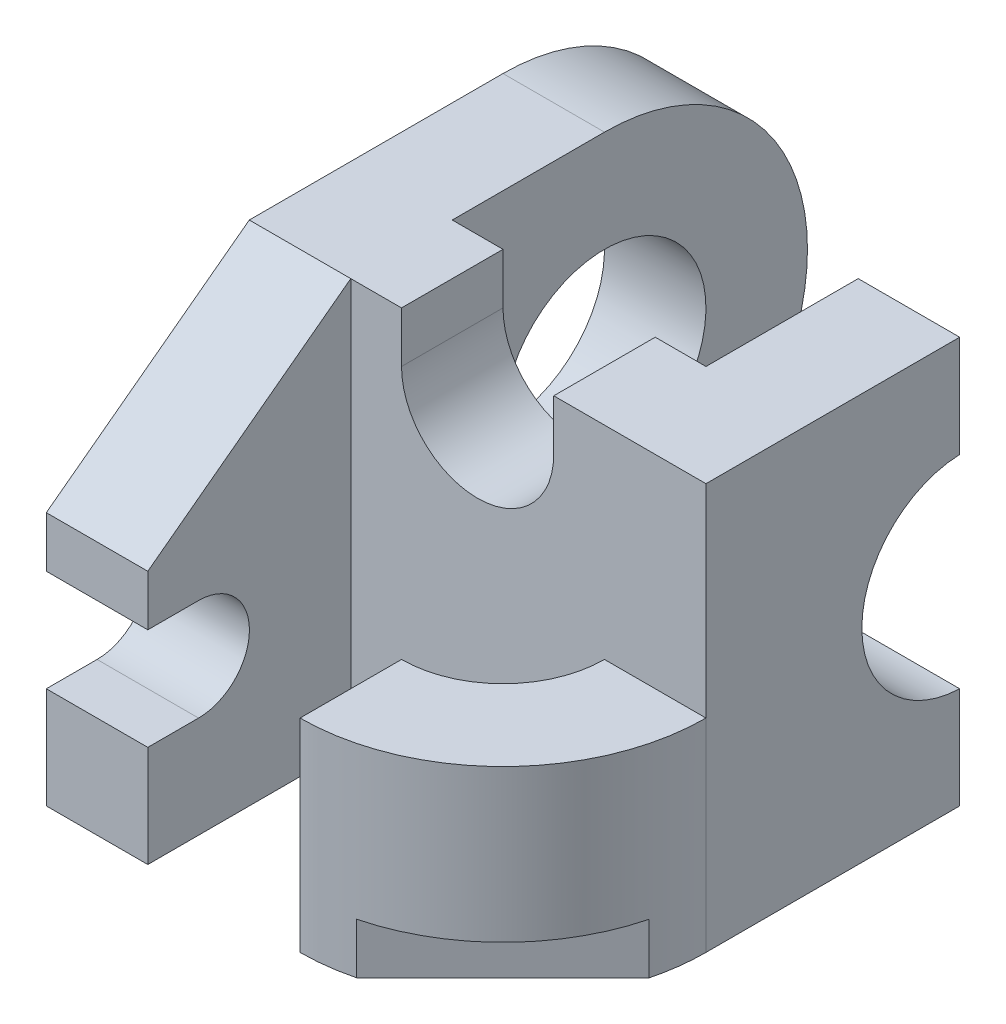
from build123d import *

# Parameters (mm, degrees)
BOSS_EXTRUDE1_DEPTH = 2
BOSS_EXTRUDE2_DEPTH = 2
SKETCH3_R           = 2
BOSS_EXTRUDE3_DEPTH = 2
BOSS_EXTRUDE4_DEPTH = 2
BOSS_EXTRUDE5_DEPTH = 4
CUT_EXTRUDE1_DEPTH  = 1


with BuildPart() as part:
    # Sketch1 → Boss-Extrude1 (new body)
    with BuildSketch(Plane.XY):
        with BuildLine():
            Line((-3, 0), (-6, 0))
            Line((-6, 0), (-6, -8))
            Line((-6, -8), (3, -8))
            Line((3, -8), (3, 0))
            Line((3, 0), (0, 0))
            Line((0, 0), (0, -1))
            ThreePointArc((0, -1), (-1.5, -2.5), (-3, -1))
            Line((-3, -1), (-3, 0))
        make_face()
    extrude(amount=BOSS_EXTRUDE1_DEPTH)

    # Sketch2 → Boss-Extrude2 (add)
    with BuildSketch(Plane(origin=(3, 0, 0), x_dir=(0, 0, -1), z_dir=(1, 0, 0))):
        with BuildLine():
            Line((0, 0), (3, 0))
            Line((3, 0), (3, -2.002573702))
            ThreePointArc((3, -2.002573702), (1.071733869, -4.001286851), (3, -6))
            Line((3, -6), (3, -8))
            Line((3, -8), (0, -8))
            Line((0, -8), (0, 0))
        make_face()
    extrude(amount=-BOSS_EXTRUDE2_DEPTH)

    # Sketch3 → Boss-Extrude3 (add)
    with BuildSketch(Plane.ZY.offset(6)):
        with BuildLine():
            Line((-3, 0), (0, 0))
            Line((0, 0), (0, -8))
            Line((0, -8), (-3, -8))
            ThreePointArc((-3, -8), (-7, -4), (-3, 0))
        make_face()
        with Locations((-3, -4)):
            Circle(SKETCH3_R, mode=Mode.SUBTRACT)
    extrude(amount=-BOSS_EXTRUDE3_DEPTH)

    # Sketch4 → Boss-Extrude4 (add)
    with BuildSketch(Plane.ZY.offset(6)):
        with BuildLine():
            Line((6, -8), (2, -8))
            Line((2, -8), (2, 0))
            Line((2, 0), (6, -2.994386604))
            Line((6, -2.994386604), (6, -3.994386604))
            Line((6, -3.994386604), (5, -3.994386604))
            ThreePointArc((5, -3.994386604), (3.997193302, -4.997193302), (5, -6))
            Line((5, -6), (6, -6))
            Line((6, -6), (6, -8))
        make_face()
    extrude(amount=-BOSS_EXTRUDE4_DEPTH)

    # Sketch5 → Boss-Extrude5 (add)
    with BuildSketch(Plane.XZ.offset(8)):
        with BuildLine():
            Line((3, 2), (1, 2))
            ThreePointArc((1, 2), (0.414213562, 3.414213562), (-1, 4))
            Line((-1, 4), (-1, 6))
            ThreePointArc((-1, 6), (1.828427125, 4.828427125), (3, 2))
        make_face()
    extrude(amount=-BOSS_EXTRUDE5_DEPTH)

    # Sketch6 → Cut-Extrude1 (cut)
    with BuildSketch(Plane.XZ.offset(8)):
        with BuildLine():
            Line((-0.007843258, 5.875), (2.872983346, 3))
            ThreePointArc((2.872983346, 3), (1.825562469, 4.831288882), (-0.007843258, 5.875))
        make_face()
    extrude(amount=-CUT_EXTRUDE1_DEPTH, mode=Mode.SUBTRACT)


solid = part.part
